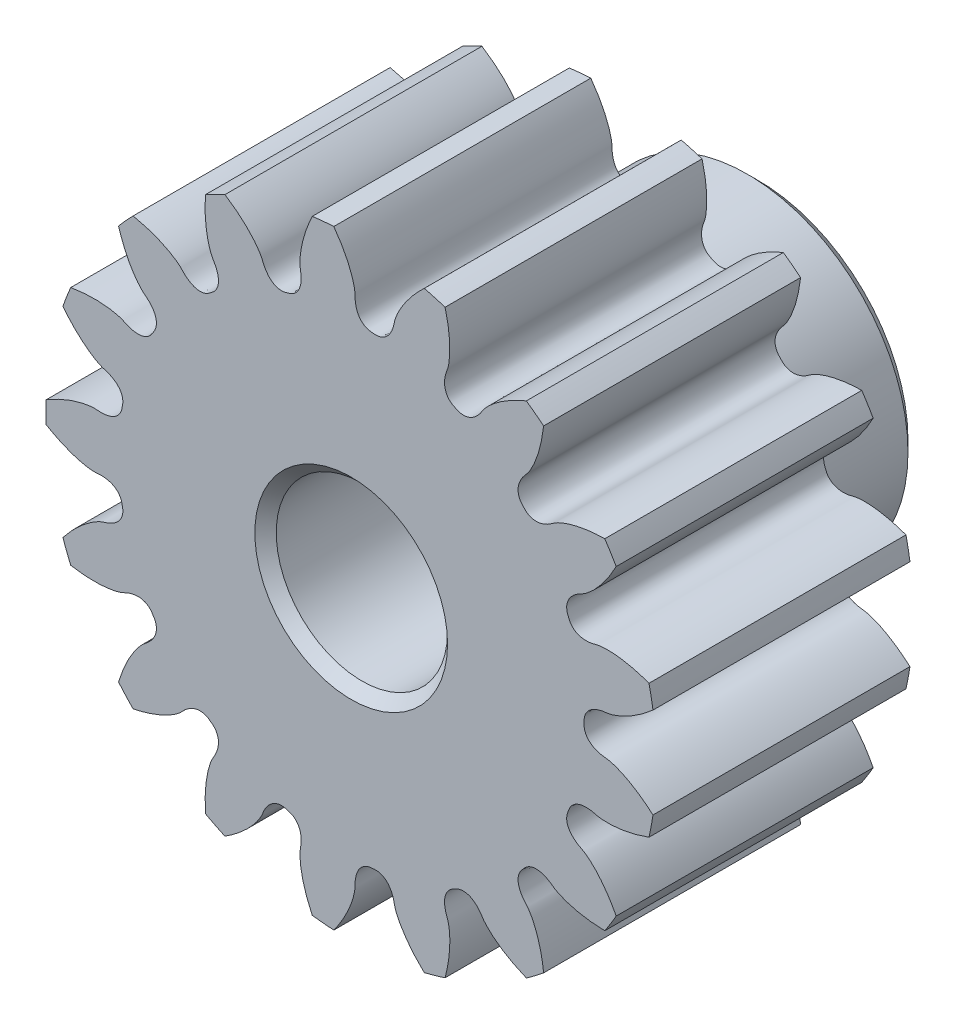
from build123d import *

# Parameters (mm, degrees)
SKETCHREVOLVESPUR01_W       = 12
SKETCHREVOLVESPUR01_H       = 14.249999786
TOOTHEXTRUDECUTSPUR01_DEPTH = 6
PATTERNSPUR01_COUNT         = 17


with BuildPart() as part:
    # SketchRevolveSpur01 → Spur01 (revolve)
    with BuildSketch(Plane(origin=(0, 0, 0), x_dir=(0, 0, -1), z_dir=(1, 0, 0))):
        with Locations((0, 7.124999893)):
            Rectangle(SKETCHREVOLVESPUR01_W, SKETCHREVOLVESPUR01_H)
    revolve(axis=Axis((0, 0, 0), (0, 0, -1)))

    # SketchToothSpur01 → ToothExtrudeCutSpur01 (cut, symmetric)
    with BuildSketch(Plane.XY):
        with BuildLine():
            ThreePointArc((14.158244182, 2.179389944), (14.324999785, 0), (14.158244182, -2.179389944))
            add(Edge.make_bspline(
                [(14.158244182, -2.179389944), (14.037117808, -2.070368927), (13.855256014, -1.91660008), (13.60967389, -1.729350296), (13.436712437, -1.606212801), (13.270534308, -1.495918256), (13.111783833, -1.397882546), (12.961074108, -1.311493215), (12.818985843, -1.236111264), (12.686066289, -1.17107251), (12.562828219, -1.115689199), (12.449749017, -1.069251304), (12.347269679, -1.031028922), (12.255794346, -1.000271367), (12.175688478, -0.976216659), (12.107281412, -0.958069734), (12.050856353, -0.945072212), (12.006675662, -0.936317286), (11.891957135, -0.917936497), (11.764189532, -0.910131696), (11.625016351, -0.878807272), (11.550056634, -0.858764967), (11.477084744, -0.834994682), (11.405808881, -0.807277473), (11.335949618, -0.774951572), (11.267241747, -0.73716424), (11.19952852, -0.692710954), (11.132917393, -0.639991871), (11.068059701, -0.577002977), (11.006538878, -0.501519152), (10.951403518, -0.411617049), (10.907034331, -0.306753966), (10.881590998, -0.19623768), (10.872948584, -0.09239376), (10.875935456, 0), (10.872948584, 0.09239376), (10.881590998, 0.19623768), (10.907034331, 0.306753966), (10.951403518, 0.411617049), (11.006538878, 0.501519152), (11.068059701, 0.577002977), (11.132917393, 0.639991871), (11.19952852, 0.692710954), (11.267241747, 0.73716424), (11.335949618, 0.774951572), (11.405808881, 0.807277473), (11.477084744, 0.834994682), (11.550056634, 0.858764967), (11.625016351, 0.878807272), (11.764189532, 0.910131696), (11.891957135, 0.917936497), (12.006675662, 0.936317286), (12.050856353, 0.945072212), (12.107281412, 0.958069734), (12.175688478, 0.976216659), (12.255794346, 1.000271367), (12.347269679, 1.031028922), (12.449749017, 1.069251304), (12.562828219, 1.115689199), (12.686066289, 1.17107251), (12.818985843, 1.236111264), (12.961074108, 1.311493215), (13.111783833, 1.397882546), (13.270534308, 1.495918256), (13.436712437, 1.606212801), (13.60967389, 1.729350296), (13.855256014, 1.91660008), (14.037117808, 2.070368927), (14.158244182, 2.179389944)],
                knots=[0, 0, 0, 0, 0.058707945, 0.085744499, 0.111236107, 0.135182769, 0.157584485, 0.178441255, 0.19775308, 0.215519958, 0.231741891, 0.246418877, 0.259550918, 0.271138013, 0.281180163, 0.289677366, 0.296629624, 0.302036936, 0.305899304, 0.338481227, 0.347945766, 0.357242682, 0.366429594, 0.375578254, 0.384778149, 0.394140499, 0.403801936, 0.413926009, 0.424698577, 0.436310124, 0.448915828, 0.462568839, 0.477143103, 0.489574491, 0.5, 0.510425509, 0.522856897, 0.537431161, 0.551084172, 0.563689876, 0.575301423, 0.586073991, 0.596198064, 0.605859501, 0.615221851, 0.624421746, 0.633570406, 0.642757318, 0.652054234, 0.661518773, 0.694100696, 0.697963064, 0.703370376, 0.710322634, 0.718819837, 0.728861987, 0.740449082, 0.753581123, 0.768258109, 0.784480042, 0.80224692, 0.821558745, 0.842415515, 0.864817231, 0.888763893, 0.914255501, 0.941292055, 1, 1, 1, 1], degree=3))
        make_face()
    toothextrudecutspur01 = extrude(amount=TOOTHEXTRUDECUTSPUR01_DEPTH, both=True, mode=Mode.SUBTRACT)

    # PatternSpur01: ToothExtrudeCutSpur01 ×17 about axis
    patternspur01_axis = Axis((0, 0, 55), (0, 0, -1))
    for i in range(1, PATTERNSPUR01_COUNT):
        add(toothextrudecutspur01.rotate(patternspur01_axis, i * 360 / PATTERNSPUR01_COUNT), mode=Mode.SUBTRACT)

    # HubSketchSide1 → HubRevolve1 (revolve)
    with BuildSketch(Plane(origin=(0, 0, 0), x_dir=(0, 0, -1), z_dir=(1, 0, 0))):
        with BuildLine():
            Line((6.5, 7.5), (12.5, 7.5))
            Line((12.5, 7.5), (13, 7))
            Line((13, 7), (13, 0))
            Line((13, 0), (6, 0))
            Line((6, 0), (6, 8))
            ThreePointArc((6, 8), (6.146446609, 7.646446609), (6.5, 7.5))
        make_face()
    revolve(axis=Axis((0, 0, 0), (0, 0, -1)))

    # BoreRevolveSketch → BoreRevolveCut (revolve, cut)
    with BuildSketch(Plane(origin=(0, 0, 0), x_dir=(0, 0, -1), z_dir=(1, 0, 0))):
        Polygon((-6, 0), (13, 0), (13, 4.5), (12.5, 4), (-5.5, 4), (-6, 4.5), align=None)
    revolve(axis=Axis((0, 0, 0), (0, 0, -1)), mode=Mode.SUBTRACT)


solid = part.part
